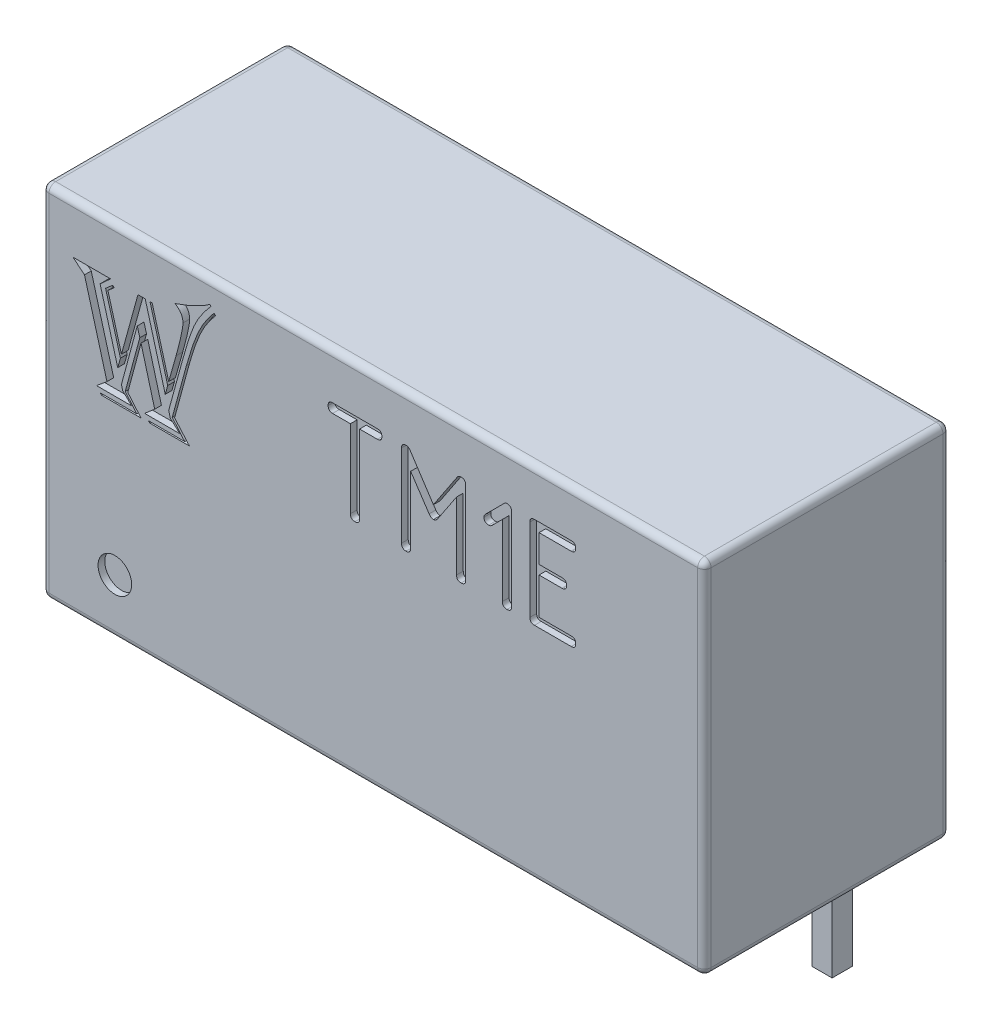
from build123d import *

# Parameters (mm, degrees)
SKETCH_2_W                         = 19.7
SKETCH_2_H                         = 7.3
EXTRUDE_1_DEPTH                    = 10.7
FILLET_1_R                         = 0.2
SKETCH_3_W                         = 0.6
SKETCH_3_H                         = 0.6
EXTRUDE_2_DEPTH                    = 4
CHAMFER_1_SIZE                     = 0.2
SKETCH_4_R                         = 0.5
CUT_EXTRUDE_1_DEPTH                = 0.2
PATTERN_LINEAR_2_COUNT             = 7
PATTERN_LINEAR_2_PITCH             = 2.54
CHAMFER_1_OF_PATTERN_LINEAR_2_SIZE = 0.2


with BuildPart() as part:
    # Эскиз2 → Бобышка-Вытянуть1 (new body)
    with BuildSketch(Plane(origin=(0, 0, 0), x_dir=(1, 0, 0), z_dir=(0, 1, 0))):
        Rectangle(SKETCH_2_W, SKETCH_2_H)
    extrude(amount=EXTRUDE_1_DEPTH)

    # Скругление1
    fillet_1_edges = [part.edges().sort_by_distance(p)[0] for p in [
        (-9.85, 10.7, 0),
        (0, 10.7, 3.65),
        (9.85, 10.7, 0),
        (0, 0, 3.65),
        (-9.85, 0, 0),
        (0, 0, -3.65),
        (9.85, 0, 0),
        (9.85, 5.35, 3.65),
        (-9.85, 5.35, 3.65),
        (-9.85, 5.35, -3.65),
        (9.85, 5.35, -3.65),
        (0, 10.7, -3.65),
    ]]
    fillet(fillet_1_edges, radius=FILLET_1_R)

    # Эскиз3 → Бобышка-Вытянуть2 (add)
    with BuildSketch(Plane.XZ):
        with Locations((-7.62, -2.38)):
            Rectangle(SKETCH_3_W, SKETCH_3_H)
    extrude_2 = extrude(amount=EXTRUDE_2_DEPTH)

    # Фаска1
    chamfer_1_edges = [part.edges().sort_by_distance(p)[0] for p in [
        (-7.32, -4, -2.38),
        (-7.62, -4, -2.08),
        (-7.92, -4, -2.38),
        (-7.62, -4, -2.68),
    ]]
    chamfer(chamfer_1_edges, length=CHAMFER_1_SIZE)

    # Эскиз4 → Вырез-Вытянуть1 (cut)
    with BuildSketch(Plane.XY.offset(3.65)):
        with Locations((-7.68950771, 1.64626856)):
            Circle(SKETCH_4_R)
        with BuildLine():
            add(Edge.make_bspline(
                [(-1.344415696, 9.182310933), (-1.344266371, 9.193129492), (-1.343986736, 9.213388959), (-1.336681075, 9.241435642), (-1.326921273, 9.26575643), (-1.311444221, 9.285324961), (-1.292475351, 9.300936794), (-1.268648064, 9.311266733), (-1.241271796, 9.318161675), (-1.221437304, 9.318538886), (-1.211035133, 9.318736714)],
                knots=[0, 0, 0, 0, 3.2331e-05, 6.0545e-05, 8.6456e-05, 0.000110333, 0.000134588, 0.000159388, 0.000187602, 0.000218717, 0.000218717, 0.000218717, 0.000218717], degree=3))
            Line((-1.211035133, 9.318736714), (0.120334321, 9.318736714))
            add(Edge.make_bspline(
                [(0.120334321, 9.318736714), (0.130736492, 9.318538886), (0.150570984, 9.318161675), (0.177947252, 9.311266733), (0.201774539, 9.300936794), (0.220743409, 9.285324961), (0.236220461, 9.26575643), (0.245980263, 9.241435642), (0.253285924, 9.213388959), (0.253565559, 9.193129492), (0.253714884, 9.182310933)],
                knots=[0, 0, 0, 0, 3.1115e-05, 5.9329e-05, 8.4128e-05, 0.000108383, 0.00013226, 0.000158172, 0.000186386, 0.000218717, 0.000218717, 0.000218717, 0.000218717], degree=3))
            add(Edge.make_bspline(
                [(0.253714884, 9.182310933), (0.253506721, 9.17171488), (0.253109537, 9.151497117), (0.246333588, 9.12341959), (0.235713285, 9.099568196), (0.22185524, 9.079051623), (0.201809069, 9.064416978), (0.178574078, 9.053182874), (0.150844395, 9.047403413), (0.131318327, 9.046411953), (0.120943365, 9.045885152)],
                knots=[0, 0, 0, 0, 3.1723e-05, 6.0529e-05, 8.5883e-05, 0.000109884, 0.000133761, 0.00015937, 0.000186852, 0.000218008, 0.000218008, 0.000218008, 0.000218008], degree=3))
            Line((0.120943365, 9.045885152), (-0.408924625, 9.045885152))
            Line((-0.408924625, 9.045885152), (-0.408924625, 6.72664687))
            add(Edge.make_bspline(
                [(-0.408924625, 6.72664687), (-0.409123847, 6.716043968), (-0.409503971, 6.695813136), (-0.416394271, 6.667823212), (-0.426740296, 6.643462653), (-0.442105441, 6.623772633), (-0.462083172, 6.60851704), (-0.485959175, 6.597567407), (-0.514423766, 6.591685723), (-0.534564433, 6.590731895), (-0.545350406, 6.590221089)],
                knots=[0, 0, 0, 0, 3.1723e-05, 6.0529e-05, 8.5883e-05, 0.000110615, 0.000134492, 0.000160653, 0.000188728, 0.000221099, 0.000221099, 0.000221099, 0.000221099], degree=3))
            add(Edge.make_bspline(
                [(-0.545350406, 6.590221089), (-0.555918226, 6.590781231), (-0.576024672, 6.591846963), (-0.604480113, 6.59725932), (-0.628120025, 6.60893511), (-0.648683127, 6.623314149), (-0.663062166, 6.643877251), (-0.674737957, 6.667517163), (-0.680150313, 6.695972604), (-0.681216045, 6.71607905), (-0.681776187, 6.72664687)],
                knots=[0, 0, 0, 0, 3.1764e-05, 6.0434e-05, 8.6043e-05, 0.000110405, 0.000134767, 0.000160375, 0.000189046, 0.00022081, 0.00022081, 0.00022081, 0.00022081], degree=3))
            Line((-0.681776187, 6.72664687), (-0.681776187, 9.045885152))
            Line((-0.681776187, 9.045885152), (-1.211644177, 9.045885152))
            add(Edge.make_bspline(
                [(-1.211644177, 9.045885152), (-1.222023494, 9.046407076), (-1.241557759, 9.047389358), (-1.269232727, 9.053230086), (-1.292506804, 9.064188778), (-1.311913095, 9.079465695), (-1.326531785, 9.099322772), (-1.336982453, 9.123461798), (-1.343825637, 9.151484696), (-1.34421279, 9.171710608), (-1.344415696, 9.182310933)],
                knots=[0, 0, 0, 0, 3.1157e-05, 5.8638e-05, 8.4247e-05, 0.000107645, 0.000132007, 0.000157361, 0.000186167, 0.00021789, 0.00021789, 0.00021789, 0.00021789], degree=3))
        make_face()
        with BuildLine():
            add(Edge.make_bspline(
                [(2.606450567, 9.318736714), (2.617669629, 9.318576919), (2.638720347, 9.318277089), (2.667824437, 9.311110872), (2.693144867, 9.301121042), (2.713485255, 9.285547476), (2.729569615, 9.265798265), (2.740193363, 9.241587062), (2.747131706, 9.213345923), (2.747930786, 9.193118581), (2.748357741, 9.182310933)],
                knots=[0, 0, 0, 0, 3.3547e-05, 6.2946e-05, 8.9416e-05, 0.000114631, 0.000138886, 0.000165047, 0.00019326, 0.000225632, 0.000225632, 0.000225632, 0.000225632], degree=3))
            Line((2.748357741, 9.182310933), (2.748357741, 6.72664687))
            add(Edge.make_bspline(
                [(2.748357741, 6.72664687), (2.748158519, 6.716043968), (2.747778395, 6.695813136), (2.740888096, 6.667823212), (2.730542071, 6.643462653), (2.715176925, 6.623772633), (2.695199194, 6.60851704), (2.671323191, 6.597567407), (2.6428586, 6.591685723), (2.622717933, 6.590731895), (2.61193196, 6.590221089)],
                knots=[0, 0, 0, 0, 3.1723e-05, 6.0529e-05, 8.5883e-05, 0.000110615, 0.000134492, 0.000160653, 0.000188728, 0.000221099, 0.000221099, 0.000221099, 0.000221099], degree=3))
            add(Edge.make_bspline(
                [(2.61193196, 6.590221089), (2.60136414, 6.590781231), (2.581257694, 6.591846963), (2.552802253, 6.59725932), (2.529162341, 6.60893511), (2.508599239, 6.623314149), (2.4942202, 6.643877251), (2.482544409, 6.667517163), (2.477132053, 6.695972604), (2.476066321, 6.71607905), (2.475506179, 6.72664687)],
                knots=[0, 0, 0, 0, 3.1764e-05, 6.0434e-05, 8.6043e-05, 0.000110405, 0.000134767, 0.000160375, 0.000189046, 0.00022081, 0.00022081, 0.00022081, 0.00022081], degree=3))
            Line((2.475506179, 6.72664687), (2.475506179, 8.735881925))
            Line((2.475506179, 8.735881925), (1.914576962, 7.892356448))
            add(Edge.make_bspline(
                [(1.914576962, 7.892356448), (1.905513698, 7.880139294), (1.888429366, 7.857109852), (1.857007015, 7.831168606), (1.823574717, 7.81407926), (1.800056553, 7.812251431), (1.788504923, 7.81135364)],
                knots=[0, 0, 0, 0, 4.5467e-05, 8.5705e-05, 0.000121395, 0.000155848, 0.000155848, 0.000155848, 0.000155848], degree=3))
            add(Edge.make_bspline(
                [(1.788504923, 7.81135364), (1.776734522, 7.812206848), (1.752708122, 7.813948464), (1.719049141, 7.831724714), (1.687150721, 7.857888061), (1.669859252, 7.881134334), (1.660605753, 7.893574535)],
                knots=[0, 0, 0, 0, 3.5056e-05, 7.1558e-05, 0.000111796, 0.000158119, 0.000158119, 0.000158119, 0.000158119], degree=3))
            Line((1.660605753, 7.893574535), (1.111248366, 8.716392528))
            Line((1.111248366, 8.716392528), (1.111248366, 6.725428783))
            add(Edge.make_bspline(
                [(1.111248366, 6.725428783), (1.111077455, 6.714815847), (1.110754539, 6.694763922), (1.103618092, 6.66708591), (1.093665514, 6.642845738), (1.07762437, 6.623854615), (1.058501648, 6.607622349), (1.033912543, 6.597997839), (1.005911146, 6.590637278), (0.985644811, 6.590365968), (0.974822585, 6.590221089)],
                knots=[0, 0, 0, 0, 3.1723e-05, 5.9937e-05, 8.5291e-05, 0.000109546, 0.000133801, 0.000159712, 0.000187926, 0.000220257, 0.000220257, 0.000220257, 0.000220257], degree=3))
            add(Edge.make_bspline(
                [(0.974822585, 6.590221089), (0.964254765, 6.590781231), (0.944148319, 6.591846963), (0.915692878, 6.59725932), (0.892052966, 6.60893511), (0.871489864, 6.623314149), (0.857110825, 6.643877251), (0.845435034, 6.667517163), (0.840022678, 6.695972604), (0.838956946, 6.71607905), (0.838396804, 6.72664687)],
                knots=[0, 0, 0, 0, 3.1764e-05, 6.0434e-05, 8.6043e-05, 0.000110405, 0.000134767, 0.000160375, 0.000189046, 0.00022081, 0.00022081, 0.00022081, 0.00022081], degree=3))
            Line((0.838396804, 6.72664687), (0.838396804, 9.182310933))
            add(Edge.make_bspline(
                [(0.838396804, 9.182310933), (0.838541683, 9.193133159), (0.838812993, 9.213399494), (0.846173553, 9.241400891), (0.855798064, 9.265989995), (0.87203033, 9.285112718), (0.891021453, 9.301153861), (0.915261625, 9.311106439), (0.942939636, 9.318242887), (0.962991562, 9.318565803), (0.973604498, 9.318736714)],
                knots=[0, 0, 0, 0, 3.2331e-05, 6.0545e-05, 8.6456e-05, 0.000110711, 0.000134966, 0.00016032, 0.000188534, 0.000220257, 0.000220257, 0.000220257, 0.000220257], degree=3))
            add(Edge.make_bspline(
                [(0.973604498, 9.318736714), (0.985504795, 9.317966788), (1.008828614, 9.316457783), (1.041867726, 9.302846556), (1.070505811, 9.280141141), (1.085290544, 9.260254006), (1.092977056, 9.24991478)],
                knots=[0, 0, 0, 0, 3.5581e-05, 6.9736e-05, 0.000105312, 0.000143836, 0.000143836, 0.000143836, 0.000143836], degree=3))
            Line((1.092977056, 9.24991478), (1.78789588, 8.193833062))
            Line((1.78789588, 8.193833062), (2.486468965, 9.243824343))
            add(Edge.make_bspline(
                [(2.486468965, 9.243824343), (2.493345007, 9.255311321), (2.50648846, 9.277268509), (2.535883061, 9.300965274), (2.569561156, 9.316159129), (2.593899291, 9.317859715), (2.606450567, 9.318736714)],
                knots=[0, 0, 0, 0, 3.9868e-05, 7.6207e-05, 0.000111395, 0.000148865, 0.000148865, 0.000148865, 0.000148865], degree=3))
        make_face()
        with BuildLine():
            Line((3.839763991, 8.840637436), (3.526106503, 8.526979948))
            add(Edge.make_bspline(
                [(3.526106503, 8.526979948), (3.519416413, 8.521200608), (3.50631719, 8.509884636), (3.483013989, 8.498055965), (3.457663496, 8.491316969), (3.440068846, 8.490331081), (3.431095691, 8.489828284)],
                knots=[0, 0, 0, 0, 2.6443e-05, 5.1775e-05, 7.7629e-05, 0.000104537, 0.000104537, 0.000104537, 0.000104537], degree=3))
            add(Edge.make_bspline(
                [(3.431095691, 8.489828284), (3.420278474, 8.489978456), (3.400021518, 8.490259678), (3.371958271, 8.497554878), (3.347426415, 8.507456612), (3.327600262, 8.523019255), (3.312540198, 8.542865576), (3.301149602, 8.566563551), (3.295671858, 8.594956541), (3.294615881, 8.615072305), (3.294060866, 8.625645022)],
                knots=[0, 0, 0, 0, 3.2331e-05, 6.0545e-05, 8.6456e-05, 0.000111188, 0.000135065, 0.000160674, 0.000189345, 0.000221108, 0.000221108, 0.000221108, 0.000221108], degree=3))
            add(Edge.make_bspline(
                [(3.294060866, 8.625645022), (3.294485372, 8.6346376), (3.29531113, 8.652130152), (3.303093367, 8.67717001), (3.315355618, 8.700296731), (3.327055034, 8.713362982), (3.333039661, 8.72004679)],
                knots=[0, 0, 0, 0, 2.6908e-05, 5.2343e-05, 7.7959e-05, 0.000104784, 0.000104784, 0.000104784, 0.000104784], degree=3))
            Line((3.333039661, 8.72004679), (3.862907651, 9.24991478))
            add(Edge.make_bspline(
                [(3.862907651, 9.24991478), (3.871726947, 9.260180566), (3.888289661, 9.279459801), (3.916257816, 9.301814324), (3.945124742, 9.316008337), (3.964890628, 9.317852819), (3.974362642, 9.318736714)],
                knots=[0, 0, 0, 0, 4.0519e-05, 7.6094e-05, 0.000106892, 0.00013523, 0.00013523, 0.00013523, 0.00013523], degree=3))
            add(Edge.make_bspline(
                [(3.974362642, 9.318736714), (3.985176023, 9.318563884), (4.00562379, 9.318237067), (4.033918963, 9.311109122), (4.058686187, 9.301135266), (4.078401278, 9.285343804), (4.094409805, 9.265810799), (4.105226825, 9.241667435), (4.111163795, 9.213248116), (4.112109238, 9.193100583), (4.112615554, 9.182310933)],
                knots=[0, 0, 0, 0, 3.2331e-05, 6.1137e-05, 8.7048e-05, 0.00011178, 0.000136035, 0.000162196, 0.000190271, 0.000222642, 0.000222642, 0.000222642, 0.000222642], degree=3))
            Line((4.112615554, 9.182310933), (4.112615554, 6.72664687))
            add(Edge.make_bspline(
                [(4.112615554, 6.72664687), (4.112416332, 6.716043968), (4.112036207, 6.695813136), (4.105145908, 6.667823212), (4.094799883, 6.643462653), (4.079434738, 6.623772633), (4.059457007, 6.60851704), (4.035581004, 6.597567407), (4.007116412, 6.591685723), (3.986975746, 6.590731895), (3.976189773, 6.590221089)],
                knots=[0, 0, 0, 0, 3.1723e-05, 6.0529e-05, 8.5883e-05, 0.000110615, 0.000134492, 0.000160653, 0.000188728, 0.000221099, 0.000221099, 0.000221099, 0.000221099], degree=3))
            add(Edge.make_bspline(
                [(3.976189773, 6.590221089), (3.965587042, 6.590420385), (3.945356538, 6.590800651), (3.917364416, 6.597690003), (3.893011037, 6.608039124), (3.87329583, 6.623393409), (3.85824547, 6.643263681), (3.846852061, 6.666954711), (3.841375179, 6.695349831), (3.840319074, 6.715465277), (3.839763991, 6.726037827)],
                knots=[0, 0, 0, 0, 3.1723e-05, 6.0529e-05, 8.5883e-05, 0.000110615, 0.000134492, 0.000160101, 0.000188771, 0.000220535, 0.000220535, 0.000220535, 0.000220535], degree=3))
            Line((3.839763991, 6.726037827), (3.839763991, 8.840637436))
        make_face()
        with BuildLine():
            Line((4.658318679, 6.72664687), (4.658318679, 9.182310933))
            add(Edge.make_bspline(
                [(4.658318679, 9.182310933), (4.658829485, 9.193096906), (4.659783313, 9.213237573), (4.665664997, 9.241702164), (4.67661463, 9.265578167), (4.691870222, 9.285555898), (4.711560243, 9.300921043), (4.735920802, 9.311267068), (4.763910726, 9.318157368), (4.784141557, 9.318537492), (4.79474446, 9.318736714)],
                knots=[0, 0, 0, 0, 3.2371e-05, 6.0447e-05, 8.6607e-05, 0.000110484, 0.000135216, 0.000160571, 0.000189376, 0.000221099, 0.000221099, 0.000221099, 0.000221099], degree=3))
            Line((4.79474446, 9.318736714), (5.88615071, 9.318736714))
            add(Edge.make_bspline(
                [(5.88615071, 9.318736714), (5.896973084, 9.318591896), (5.917239696, 9.318320701), (5.945239267, 9.310959386), (5.969834442, 9.301337384), (5.988936251, 9.285096473), (6.005177161, 9.265994664), (6.014799163, 9.24139949), (6.022160478, 9.213399919), (6.022431673, 9.193133307), (6.022576491, 9.182310933)],
                knots=[0, 0, 0, 0, 3.2331e-05, 6.0545e-05, 8.6456e-05, 0.000110711, 0.000134966, 0.000160877, 0.000189091, 0.000221422, 0.000221422, 0.000221422, 0.000221422], degree=3))
            add(Edge.make_bspline(
                [(6.022576491, 9.182310933), (6.022377269, 9.17170803), (6.021997145, 9.151477198), (6.015106846, 9.123487274), (6.004760821, 9.099126715), (5.989395675, 9.079436695), (5.969417944, 9.064181102), (5.945541941, 9.053231469), (5.91707735, 9.047349786), (5.896936683, 9.046395957), (5.88615071, 9.045885152)],
                knots=[0, 0, 0, 0, 3.1723e-05, 6.0529e-05, 8.5883e-05, 0.000110615, 0.000134492, 0.000160653, 0.000188728, 0.000221099, 0.000221099, 0.000221099, 0.000221099], degree=3))
            Line((5.88615071, 9.045885152), (4.931170241, 9.045885152))
            Line((4.931170241, 9.045885152), (4.931170241, 8.227330464))
            Line((4.931170241, 8.227330464), (5.613299148, 8.227330464))
            add(Edge.make_bspline(
                [(5.613299148, 8.227330464), (5.624121522, 8.227185646), (5.644388133, 8.226914451), (5.672387705, 8.219553136), (5.696982879, 8.209931134), (5.716084688, 8.193690223), (5.732325598, 8.174588414), (5.7419476, 8.14999324), (5.749308915, 8.121993669), (5.749580111, 8.101727057), (5.749724929, 8.090904683)],
                knots=[0, 0, 0, 0, 3.2331e-05, 6.0545e-05, 8.6456e-05, 0.000110711, 0.000134966, 0.000160877, 0.000189091, 0.000221422, 0.000221422, 0.000221422, 0.000221422], degree=3))
            add(Edge.make_bspline(
                [(5.749724929, 8.090904683), (5.749525707, 8.08030178), (5.749145582, 8.060070948), (5.742255283, 8.032081024), (5.731909258, 8.007720465), (5.716544113, 7.988030445), (5.696566382, 7.972774852), (5.672690379, 7.961825219), (5.644225787, 7.955943536), (5.624085121, 7.954989707), (5.613299148, 7.954478902)],
                knots=[0, 0, 0, 0, 3.1723e-05, 6.0529e-05, 8.5883e-05, 0.000110615, 0.000134492, 0.000160653, 0.000188728, 0.000221099, 0.000221099, 0.000221099, 0.000221099], degree=3))
            Line((5.613299148, 7.954478902), (4.931170241, 7.954478902))
            Line((4.931170241, 7.954478902), (4.931170241, 6.863072652))
            Line((4.931170241, 6.863072652), (5.88615071, 6.863072652))
            add(Edge.make_bspline(
                [(5.88615071, 6.863072652), (5.896973084, 6.862927833), (5.917239696, 6.862656638), (5.945239267, 6.855295323), (5.969834442, 6.845673321), (5.988936251, 6.829432411), (6.005177161, 6.810330602), (6.014799163, 6.785735427), (6.022160478, 6.757735856), (6.022431673, 6.737469244), (6.022576491, 6.72664687)],
                knots=[0, 0, 0, 0, 3.2331e-05, 6.0545e-05, 8.6456e-05, 0.000110711, 0.000134966, 0.000160877, 0.000189091, 0.000221422, 0.000221422, 0.000221422, 0.000221422], degree=3))
            add(Edge.make_bspline(
                [(6.022576491, 6.72664687), (6.022377269, 6.716043968), (6.021997145, 6.695813136), (6.015106846, 6.667823212), (6.004760821, 6.643462653), (5.989395675, 6.623772633), (5.969417944, 6.60851704), (5.945541941, 6.597567407), (5.91707735, 6.591685723), (5.896936683, 6.590731895), (5.88615071, 6.590221089)],
                knots=[0, 0, 0, 0, 3.1723e-05, 6.0529e-05, 8.5883e-05, 0.000110615, 0.000134492, 0.000160653, 0.000188728, 0.000221099, 0.000221099, 0.000221099, 0.000221099], degree=3))
            Line((5.88615071, 6.590221089), (4.79474446, 6.590221089))
            add(Edge.make_bspline(
                [(4.79474446, 6.590221089), (4.78417664, 6.590781231), (4.764070194, 6.591846963), (4.735614753, 6.59725932), (4.711974841, 6.60893511), (4.691411739, 6.623314149), (4.6770327, 6.643877251), (4.665356909, 6.667517163), (4.659944553, 6.695972604), (4.658878821, 6.71607905), (4.658318679, 6.72664687)],
                knots=[0, 0, 0, 0, 3.1764e-05, 6.0434e-05, 8.6043e-05, 0.000110405, 0.000134767, 0.000160375, 0.000189046, 0.00022081, 0.00022081, 0.00022081, 0.00022081], degree=3))
        make_face()
        with BuildLine():
            add(Edge.make_bspline(
                [(-4.826920529, 9.99808571), (-4.877635504, 9.940076399), (-4.976256976, 9.827270199), (-5.106321335, 9.650843506), (-5.218113707, 9.475770751), (-5.295816993, 9.325229448), (-5.351641753, 9.197924187), (-5.393852102, 9.088650364), (-5.439966404, 8.965985236), (-5.485301464, 8.828052847), (-5.534904487, 8.676531281), (-5.584495653, 8.510075747), (-5.637137079, 8.32973205), (-5.671825467, 8.204587794), (-5.689805925, 8.139720236)],
                knots=[0, 0, 0, 0, 0.000231072, 0.000449347, 0.000656859, 0.000853626, 0.000956844, 0.001073769, 0.001205006, 0.001349934, 0.001509276, 0.001683302, 0.001870948, 0.002072885, 0.002072885, 0.002072885, 0.002072885], degree=3))
            Line((-5.689805925, 8.139720236), (-6.08691, 6.690698346))
            Line((-6.08691, 6.690698346), (-6.041351827, 6.508465654))
            Line((-6.041351827, 6.508465654), (-5.758483171, 6.251435962))
            Line((-5.758483171, 6.251435962), (-6.804961204, 6.251435962))
            Line((-6.804961204, 6.251435962), (-6.504413256, 6.508465654))
            Line((-6.504413256, 6.508465654), (-6.91103695, 8.007125554))
            Line((-6.91103695, 8.007125554), (-7.305421134, 6.541104345))
            Line((-7.305421134, 6.541104345), (-6.91103695, 6.077362943))
            Line((-6.91103695, 6.077362943), (-8.083309938, 6.077362943))
            Line((-8.083309938, 6.077362943), (-8.129548084, 6.120881198))
            Line((-8.129548084, 6.120881198), (-7.036831905, 6.120881198))
            Line((-7.036831905, 6.120881198), (-7.38157808, 6.526824918))
            Line((-7.38157808, 6.526824918), (-6.947755477, 8.126800754))
            Line((-6.947755477, 8.126800754), (-7.02323245, 8.395389983))
            Line((-7.02323245, 8.395389983), (-7.49377358, 6.653299846))
            Line((-7.49377358, 6.653299846), (-7.457055053, 6.508465654))
            Line((-7.457055053, 6.508465654), (-7.188465824, 6.251435962))
            Line((-7.188465824, 6.251435962), (-8.236983775, 6.251435962))
            Line((-8.236983775, 6.251435962), (-7.924876292, 6.508465654))
            Line((-7.924876292, 6.508465654), (-8.593289486, 8.927128659))
            Line((-8.593289486, 8.927128659), (-8.937355688, 9.210677288))
            Line((-8.937355688, 9.210677288), (-7.814720709, 9.210677288))
            Line((-7.814720709, 9.210677288), (-8.129548084, 8.927128659))
            Line((-8.129548084, 8.927128659), (-7.603929163, 7.030004739))
            Line((-7.603929163, 7.030004739), (-7.52369238, 7.312873395))
            Line((-7.52369238, 7.312873395), (-7.966354628, 8.893130022))
            Line((-7.966354628, 8.893130022), (-7.757603, 9.075362714))
            Line((-7.757603, 9.075362714), (-7.704565127, 9.039324159))
            Line((-7.704565127, 9.039324159), (-7.895637464, 8.873410813))
            Line((-7.895637464, 8.873410813), (-7.49377358, 7.429828705))
            Line((-7.49377358, 7.429828705), (-7.002833268, 9.210677288))
            Line((-7.002833268, 9.210677288), (-6.78660194, 9.210677288))
            Line((-6.78660194, 9.210677288), (-6.190265855, 7.049043976))
            Line((-6.190265855, 7.049043976), (-6.1168288, 7.312873395))
            Line((-6.1168288, 7.312873395), (-6.644487639, 9.210677288))
            Line((-6.644487639, 9.210677288), (-6.580570202, 9.210677288))
            Line((-6.580570202, 9.210677288), (-6.08691, 7.429828705))
            Line((-6.08691, 7.429828705), (-5.868638753, 8.2029577))
            add(Edge.make_bspline(
                [(-5.868638753, 8.2029577), (-5.852399918, 8.260941423), (-5.821497941, 8.371282573), (-5.779709212, 8.529207611), (-5.745362849, 8.671530243), (-5.715577342, 8.797792909), (-5.6929154, 8.908429472), (-5.677234564, 9.003247309), (-5.666754945, 9.08193757), (-5.664820039, 9.129284849), (-5.663966961, 9.150159714)],
                knots=[0, 0, 0, 0, 0.000180644, 0.000343759, 0.000490044, 0.000619854, 0.000732938, 0.00082874, 0.000908189, 0.000970839, 0.000970839, 0.000970839, 0.000970839], degree=3))
            add(Edge.make_bspline(
                [(-5.663966961, 9.150159714), (-5.664444102, 9.170174469), (-5.665374575, 9.209205242), (-5.677832358, 9.265815606), (-5.696071493, 9.319093511), (-5.721278692, 9.369687349), (-5.755483305, 9.415862075), (-5.79548155, 9.459856387), (-5.843949079, 9.499529133), (-5.879944069, 9.522477437), (-5.898557553, 9.534344308)],
                knots=[0, 0, 0, 0, 5.9934e-05, 0.000116878, 0.000173003, 0.000228653, 0.000285645, 0.000344834, 0.000406648, 0.000472843, 0.000472843, 0.000472843, 0.000472843], degree=3))
            add(Edge.make_bspline(
                [(-5.898557553, 9.534344308), (-5.852854058, 9.549348083), (-5.759150323, 9.580109621), (-5.617782387, 9.635379725), (-5.471123362, 9.6968715), (-5.323941724, 9.764902592), (-5.183579625, 9.833679594), (-5.059185033, 9.901732221), (-4.953287658, 9.964804983), (-4.891923173, 10.009461396), (-4.863639056, 10.030044428)],
                knots=[0, 0, 0, 0, 0.000144284, 0.000295819, 0.000455195, 0.00062132, 0.000782187, 0.000923988, 0.00104667, 0.001151565, 0.001151565, 0.001151565, 0.001151565], degree=3))
            Line((-4.863639056, 10.030044428), (-4.826920529, 9.99808571))
        make_face()
        with BuildLine():
            add(Edge.make_bspline(
                [(-4.689566037, 9.823332718), (-4.734443021, 9.771697544), (-4.824111341, 9.66852574), (-4.94261163, 9.500409015), (-5.050747144, 9.324046548), (-5.130330435, 9.168024735), (-5.189103399, 9.034547574), (-5.233486576, 8.924608961), (-5.279663273, 8.805516723), (-5.323731783, 8.676286079), (-5.369498265, 8.538085097), (-5.415864969, 8.390388815), (-5.461873835, 8.232995082), (-5.491636742, 8.124577904), (-5.50689326, 8.069003072)],
                knots=[0, 0, 0, 0, 0.000205119, 0.000409846, 0.000616142, 0.000825366, 0.000934658, 0.001053604, 0.001181023, 0.00131779, 0.001463149, 0.001617778, 0.001782168, 0.001955059, 0.001955059, 0.001955059, 0.001955059], degree=3))
            Line((-5.50689326, 8.069003072), (-5.91283698, 6.581902709))
            Line((-5.91283698, 6.581902709), (-5.472214651, 6.077362943))
            Line((-5.472214651, 6.077362943), (-6.649247448, 6.077362943))
            Line((-6.649247448, 6.077362943), (-6.702285321, 6.120881198))
            Line((-6.702285321, 6.120881198), (-5.611609061, 6.120881198))
            Line((-5.611609061, 6.120881198), (-5.983554145, 6.558103664))
            Line((-5.983554145, 6.558103664), (-5.561291079, 8.10096179))
            add(Edge.make_bspline(
                [(-5.561291079, 8.10096179), (-5.545810979, 8.15653854), (-5.515744157, 8.26448463), (-5.469295995, 8.421058195), (-5.424003878, 8.568105942), (-5.378609024, 8.70501873), (-5.333606298, 8.831933995), (-5.289414087, 8.948917071), (-5.246347229, 9.056461553), (-5.187951552, 9.186555201), (-5.109367116, 9.341365894), (-5.001658755, 9.520549148), (-4.879052144, 9.695048433), (-4.787979013, 9.805989172), (-4.741923938, 9.862091164)],
                knots=[0, 0, 0, 0, 0.000173074, 0.00033616, 0.000489937, 0.00063465, 0.000768851, 0.00089388, 0.001009795, 0.001116325, 0.001321593, 0.001530216, 0.001743012, 0.001960709, 0.001960709, 0.001960709, 0.001960709], degree=3))
            Line((-4.741923938, 9.862091164), (-4.689566037, 9.823332718))
        make_face()
    extrude(amount=-CUT_EXTRUDE_1_DEPTH, mode=Mode.SUBTRACT)

    # Линейный массив2: Бобышка-Вытянуть2 ×7, 2 skipped
    with Locations(*[(i * PATTERN_LINEAR_2_PITCH, 0, 0) for i in range(1, PATTERN_LINEAR_2_COUNT) if i not in (2, 3)]):
        add(extrude_2)

    # Фаска1 of Линейный массив2
    chamfer_1_of_pattern_linear_2_edges = [part.edges().sort_by_distance(p)[0] for p in [
        (-4.78, -4, -2.38),
        (-5.08, -4, -2.08),
        (-5.38, -4, -2.38),
        (-5.08, -4, -2.68),
        (2.84, -4, -2.38),
        (2.54, -4, -2.08),
        (2.24, -4, -2.38),
        (2.54, -4, -2.68),
        (5.38, -4, -2.38),
        (5.08, -4, -2.08),
        (4.78, -4, -2.38),
        (5.08, -4, -2.68),
        (7.92, -4, -2.38),
        (7.62, -4, -2.08),
        (7.32, -4, -2.38),
        (7.62, -4, -2.68),
    ]]
    chamfer(chamfer_1_of_pattern_linear_2_edges, length=CHAMFER_1_OF_PATTERN_LINEAR_2_SIZE)


solid = part.part
